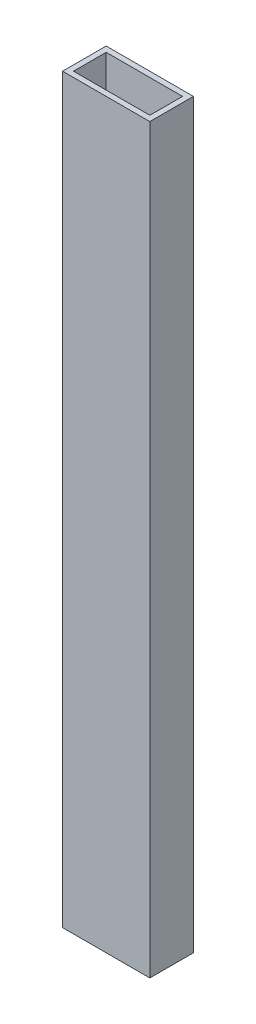
from build123d import *

# Parameters (mm, degrees)
SKETCH1_W           = 50.8
SKETCH1_H           = 25.4
SKETCH1_W_2         = 44.45
SKETCH1_H_2         = 19.05
BOSS_EXTRUDE1_DEPTH = 431.8


with BuildPart() as part:
    # Sketch1 → Boss-Extrude1 (new body)
    with BuildSketch(Plane(origin=(0, 0, 0), x_dir=(1, 0, 0), z_dir=(0, 1, 0))):
        with Locations((25.4, 12.7)):
            Rectangle(SKETCH1_W, SKETCH1_H)
        with Locations((25.4, 12.7)):
            Rectangle(SKETCH1_W_2, SKETCH1_H_2, mode=Mode.SUBTRACT)
    extrude(amount=BOSS_EXTRUDE1_DEPTH)


solid = part.part
